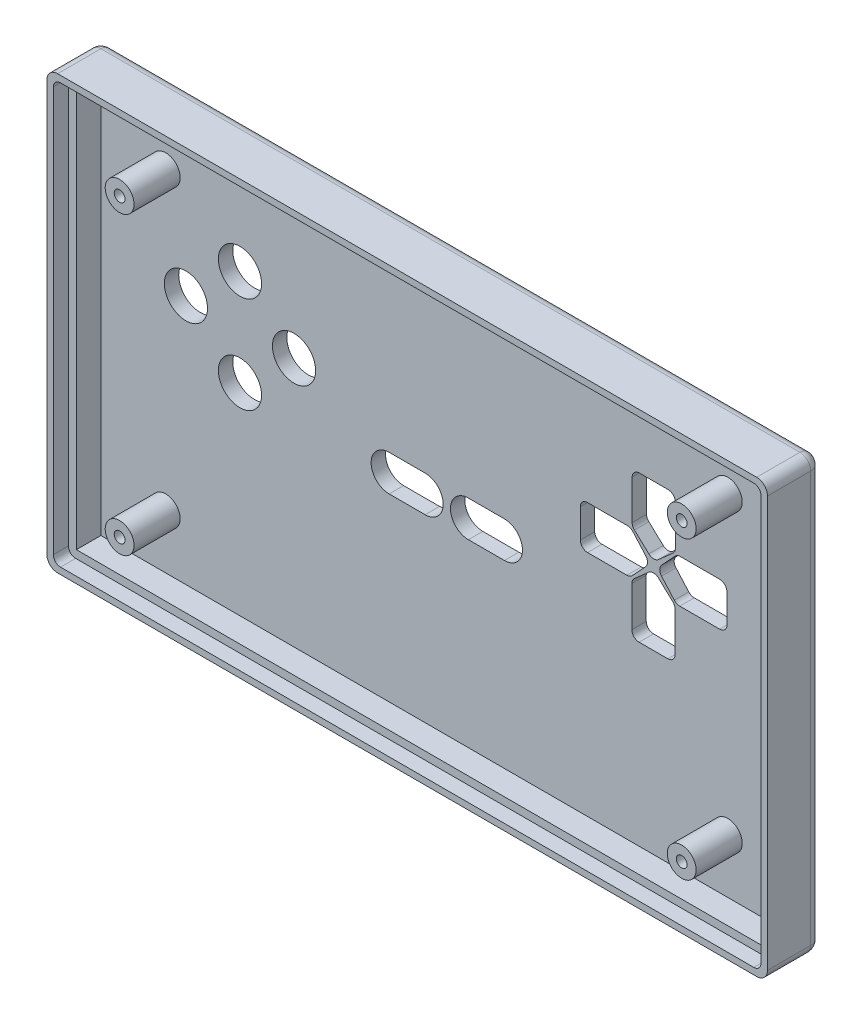
from build123d import *

# Parameters (mm, degrees)
SKETCH_1_W          = 100
SKETCH_1_H          = 60
EXTRUDE_1_DEPTH     = 2
SKETCH_2_W          = 96
SKETCH_2_H          = 56
EXTRUDE_2_DEPTH     = 5.5
SKETCH_3_W          = 98.2
SKETCH_3_H          = 58.2
SKETCH_3_W_2        = 96
SKETCH_3_H_2        = 56
CUT_EXTRUDE_1_DEPTH = 2.1
FILLET_1_R          = 1.5
FILLET_2_R          = 1
SKETCH_4_R          = 2
EXTRUDE_3_DEPTH     = 6.4
SKETCH_5_R          = 0.75
CUT_EXTRUDE_3_DEPTH = 5.5
SKETCH_6_R          = 3
CUT_EXTRUDE_4_DEPTH = 10


with BuildPart() as part:
    # 草图1 → 凸台-拉伸1 (new body)
    with BuildSketch(Plane.XY):
        Rectangle(SKETCH_1_W, SKETCH_1_H)
    extrude(amount=EXTRUDE_1_DEPTH)

    # 草图2 → 凸台-拉伸2 (add)
    with BuildSketch(Plane.XY.offset(2)):
        Polygon((-48, 30), (-50, 30), (-50, 28), (-50, -28), (-50, -30), (-48, -30), (48, -30), (50, -30), (50, -28), (50, 28), (50, 30), (48, 30), align=None)
        Rectangle(SKETCH_2_W, SKETCH_2_H, mode=Mode.SUBTRACT)
    extrude(amount=EXTRUDE_2_DEPTH)

    # 草图3 → 切除-拉伸1 (cut)
    with BuildSketch(Plane.XY.offset(7.5)):
        Rectangle(SKETCH_3_W, SKETCH_3_H)
        Rectangle(SKETCH_3_W_2, SKETCH_3_H_2, mode=Mode.SUBTRACT)
    extrude(amount=-CUT_EXTRUDE_1_DEPTH, mode=Mode.SUBTRACT)

    # 圆角1
    fillet_1_edges = [part.edges().sort_by_distance(p)[0] for p in [
        (0, 30, 0),
        (50, 0, 0),
        (0, -30, 0),
        (-50, 0, 0),
        (-50, 30, 3.75),
        (50, 30, 3.75),
        (50, -30, 3.75),
        (-50, -30, 3.75),
    ]]
    fillet(fillet_1_edges, radius=FILLET_1_R)

    # 圆角2
    fillet_2_edges = [part.edges().sort_by_distance(p)[0] for p in [
        (-49.1, -29.1, 6.45),
        (-49.1, 29.1, 6.45),
        (49.1, 29.1, 6.45),
        (49.1, -29.1, 6.45),
    ]]
    fillet(fillet_2_edges, radius=FILLET_2_R)

    # 草图4 → 凸台-拉伸3 (add)
    with BuildSketch(Plane.XY.offset(2)):
        with Locations((-39, 20.5)):
            Circle(SKETCH_4_R)
        with Locations((39, 20.5)):
            Circle(SKETCH_4_R)
        with Locations((39, -20.5)):
            Circle(SKETCH_4_R)
        with Locations((-39, -20.5)):
            Circle(SKETCH_4_R)
    extrude(amount=EXTRUDE_3_DEPTH)

    # 草图5 → 切除-拉伸3 (cut)
    with BuildSketch(Plane.XY.offset(8.4)):
        with Locations((-39, 20.5)):
            Circle(SKETCH_5_R)
        with Locations((39, 20.5)):
            Circle(SKETCH_5_R)
        with Locations((39, -20.5)):
            Circle(SKETCH_5_R)
        with Locations((-39, -20.5)):
            Circle(SKETCH_5_R)
    extrude(amount=-CUT_EXTRUDE_3_DEPTH, mode=Mode.SUBTRACT)

    # 草图6 → 切除-拉伸4 (cut)
    with BuildSketch(Plane(origin=(0, 0, 0), x_dir=(-1, 0, 0), z_dir=(0, 0, -1))):
        with BuildLine():
            ThreePointArc((3, -3), (0.5, -0.5), (3, 2))
            Line((3, 2), (8, 2))
            ThreePointArc((8, 2), (10.5, -0.5), (8, -3))
            Line((8, -3), (3, -3))
        make_face()
        with Locations((21.2, 6.7)):
            Circle(SKETCH_6_R)
        with Locations((28.7, 13.4)):
            Circle(SKETCH_6_R)
        with Locations((36.2, 6.7)):
            Circle(SKETCH_6_R)
        with Locations((28.7, 0)):
            Circle(SKETCH_6_R)
        with BuildLine():
            Line((-26.039757501, 9.676852248), (-28.035430168, 7.818756103))
            ThreePointArc((-28.035430168, 7.818756103), (-28.704377925, 7.550717722), (-29.379807919, 7.801974559))
            Line((-29.379807919, 7.801974559), (-31.384135252, 9.576820114))
            ThreePointArc((-31.384135252, 9.576820114), (-31.633039063, 9.914966319), (-31.721187045, 10.325485376))
            Line((-31.721187045, 10.325485376), (-31.721187045, 15.875281781))
            ThreePointArc((-31.721187045, 15.875281781), (-31.428293826, 16.582388562), (-30.721187045, 16.875281781))
            Line((-30.721187045, 16.875281781), (-26.721187045, 16.875281781))
            ThreePointArc((-26.721187045, 16.875281781), (-26.014080264, 16.582388562), (-25.721187045, 15.875281781))
            Line((-25.721187045, 15.875281781), (-25.721187045, 10.408735966))
            ThreePointArc((-25.721187045, 10.408735966), (-25.804282049, 10.009630431), (-26.039757501, 9.676852248))
        make_face()
        with BuildLine():
            Line((-25.723147752, 4.039757501), (-27.581243897, 6.035430168))
            ThreePointArc((-27.581243897, 6.035430168), (-27.849282278, 6.704377925), (-27.598025441, 7.379807919))
            Line((-27.598025441, 7.379807919), (-25.823179886, 9.384135252))
            ThreePointArc((-25.823179886, 9.384135252), (-25.485033681, 9.633039063), (-25.074514624, 9.721187045))
            Line((-25.074514624, 9.721187045), (-19.524718219, 9.721187045))
            ThreePointArc((-19.524718219, 9.721187045), (-18.817611438, 9.428293826), (-18.524718219, 8.721187045))
            Line((-18.524718219, 8.721187045), (-18.524718219, 4.721187045))
            ThreePointArc((-18.524718219, 4.721187045), (-18.817611438, 4.014080264), (-19.524718219, 3.721187045))
            Line((-19.524718219, 3.721187045), (-24.991264034, 3.721187045))
            ThreePointArc((-24.991264034, 3.721187045), (-25.390369569, 3.804282049), (-25.723147752, 4.039757501))
        make_face()
        with BuildLine():
            Line((-31.360242499, 3.723147752), (-29.364569832, 5.581243897))
            ThreePointArc((-29.364569832, 5.581243897), (-28.695622075, 5.849282278), (-28.020192081, 5.598025441))
            Line((-28.020192081, 5.598025441), (-26.015864748, 3.823179886))
            ThreePointArc((-26.015864748, 3.823179886), (-25.766960937, 3.485033681), (-25.678812955, 3.074514624))
            Line((-25.678812955, 3.074514624), (-25.678812955, -2.475281781))
            ThreePointArc((-25.678812955, -2.475281781), (-25.971706174, -3.182388562), (-26.678812955, -3.475281781))
            Line((-26.678812955, -3.475281781), (-30.678812955, -3.475281781))
            ThreePointArc((-30.678812955, -3.475281781), (-31.385919736, -3.182388562), (-31.678812955, -2.475281781))
            Line((-31.678812955, -2.475281781), (-31.678812955, 2.991264034))
            ThreePointArc((-31.678812955, 2.991264034), (-31.595717951, 3.390369569), (-31.360242499, 3.723147752))
        make_face()
        with BuildLine():
            Line((-29.801974559, 6.020192081), (-31.576820114, 4.015864748))
            ThreePointArc((-31.576820114, 4.015864748), (-31.914966319, 3.766960937), (-32.325485376, 3.678812955))
            Line((-32.325485376, 3.678812955), (-37.875281781, 3.678812955))
            ThreePointArc((-37.875281781, 3.678812955), (-38.582388562, 3.971706174), (-38.875281781, 4.678812955))
            Line((-38.875281781, 4.678812955), (-38.875281781, 8.678812955))
            ThreePointArc((-38.875281781, 8.678812955), (-38.582388562, 9.385919736), (-37.875281781, 9.678812955))
            Line((-37.875281781, 9.678812955), (-32.408735966, 9.678812955))
            ThreePointArc((-32.408735966, 9.678812955), (-32.009630431, 9.595717951), (-31.676852248, 9.360242499))
            Line((-31.676852248, 9.360242499), (-29.818756103, 7.364569832))
            ThreePointArc((-29.818756103, 7.364569832), (-29.550717722, 6.695622075), (-29.801974559, 6.020192081))
        make_face()
        with BuildLine():
            Line((-8, 2), (-3, 2))
            ThreePointArc((-3, 2), (-0.5, -0.5), (-3, -3))
            Line((-3, -3), (-8, -3))
            ThreePointArc((-8, -3), (-10.5, -0.5), (-8, 2))
        make_face()
    extrude(amount=-CUT_EXTRUDE_4_DEPTH, mode=Mode.SUBTRACT)


solid = part.part
